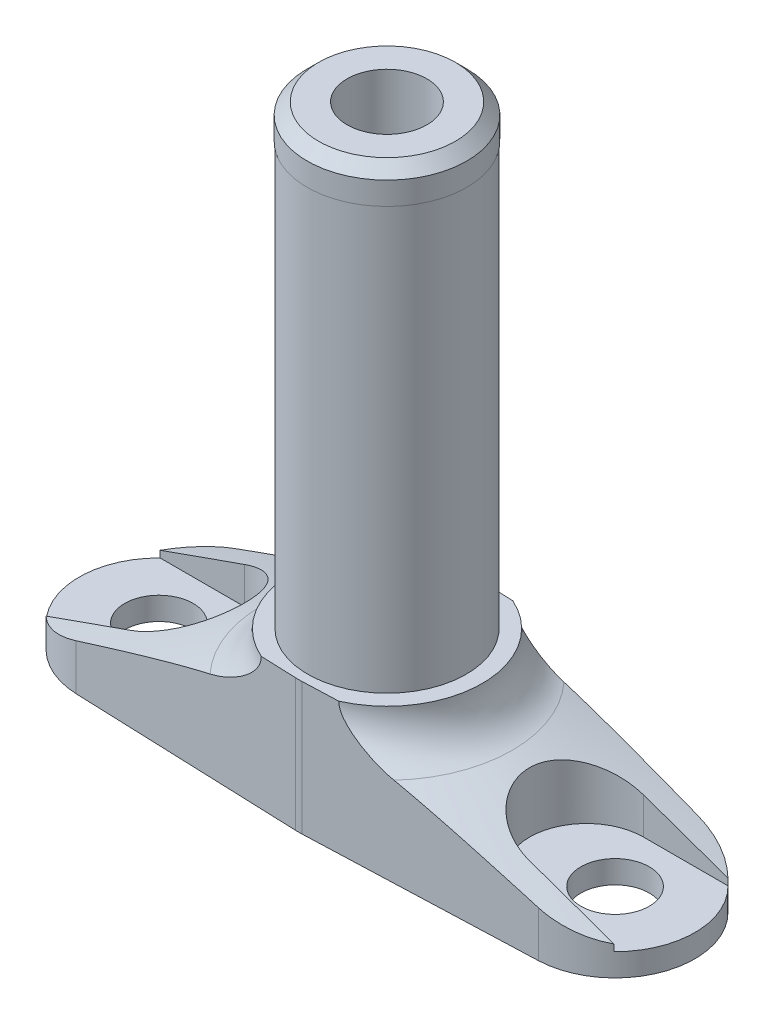
from build123d import *

# Parameters (mm, degrees)
SZKIC1_W                        = 27
SZKIC1_H                        = 25
ZAOKR_GLENIE1_R                 = 4
SZKIC4_R                        = 3
WYTNIJ_WYCI_GNI_CIE3_DEPTH      = 24.0000001
WYTNIJ_WYCI_GNI_CIE3_DEPTH_BACK = 3
WYTNIJ_WYCI_GNI_CIE2_DEPTH      = 24.0000001
SZKIC5_OUTSIDE_W                = 72.072
SZKIC5_OUTSIDE_H                = 72.072
WYTNIJ_WYCI_GNI_CIE4_DEPTH      = 26.0000001
SZKIC8_W                        = 8.35
SZKIC8_H                        = 13.411124978
SZKIC10_R                       = 3.5
WYTNIJ_WYCI_GNI_CIE5_DEPTH      = 52.588875122


with BuildPart() as part:
    # Szkic1 → Obrót1 (revolve)
    with BuildSketch(Plane.XY):
        with Locations((13.5, 12.5)):
            Rectangle(SZKIC1_W, SZKIC1_H)
    revolve(axis=Axis((0, 0, 0), (0, 1, 0)))

    # Szkic2 → Wycięcie-obrót1 (revolve, cut)
    with BuildSketch(Plane.XY):
        Polygon((27, 25), (27, 2), (8.35, 8.788044869), (8.35, 25), align=None)
    revolve(axis=Axis((0, 0, 0), (0, 1, 0)), mode=Mode.SUBTRACT)

    # Zaokrąglenie1
    zaokr_glenie1_edges = [part.edges().sort_by_distance(p)[0] for p in [
        (-8.35, 8.788044869, 0),
    ]]
    fillet(zaokr_glenie1_edges, radius=ZAOKR_GLENIE1_R)

    # Szkic4 → Wytnij-wyciągnięcie3 (cut, two sides)
    with BuildSketch(Plane(origin=(0, 2, 0), x_dir=(1, 0, 0), z_dir=(0, 1, 0))) as wytnij_wyci_gni_cie3_sk:
        with Locations((-20, 0)):
            Circle(SZKIC4_R)
        with Locations((20, 0)):
            Circle(SZKIC4_R)
    extrude(amount=WYTNIJ_WYCI_GNI_CIE3_DEPTH, mode=Mode.SUBTRACT)
    extrude(wytnij_wyci_gni_cie3_sk.sketch, amount=-WYTNIJ_WYCI_GNI_CIE3_DEPTH_BACK, mode=Mode.SUBTRACT)

    # Szkic3 → Wytnij-wyciągnięcie2 (cut, through all)
    with BuildSketch(Plane(origin=(0, 2, 0), x_dir=(1, 0, 0), z_dir=(0, 1, 0))):
        with BuildLine():
            Line((-17.5, 5), (-26.532998323, 5))
            ThreePointArc((-26.532998323, 5), (-27, 0), (-26.532998323, -5))
            Line((-26.532998323, -5), (-17.5, -5))
            ThreePointArc((-17.5, -5), (-12.5, 0), (-17.5, 5))
        make_face()
        with BuildLine():
            Line((17.5, 5), (26.532998323, 5))
            ThreePointArc((26.532998323, 5), (27, 0), (26.532998323, -5))
            Line((26.532998323, -5), (17.5, -5))
            ThreePointArc((17.5, -5), (12.5, 0), (17.5, 5))
        make_face()
    extrude(amount=WYTNIJ_WYCI_GNI_CIE2_DEPTH, mode=Mode.SUBTRACT)

    # Szkic5 outside → Wytnij-wyciągnięcie4 (cut, through all)
    with BuildSketch(Plane.XZ):
        Rectangle(SZKIC5_OUTSIDE_W, SZKIC5_OUTSIDE_H)
        with BuildLine():
            Line((-20.2625, 6.995076393), (-0.290625, 7.744548864))
            ThreePointArc((-0.290625, 7.744548864), (0, 7.75), (0.290625, 7.744548864))
            Line((0.290625, 7.744548864), (20.2625, 6.995076393))
            ThreePointArc((20.2625, 6.995076393), (27, 0), (20.2625, -6.995076393))
            Line((20.2625, -6.995076393), (0.290625, -7.744548864))
            ThreePointArc((0.290625, -7.744548864), (0, -7.75), (-0.290625, -7.744548864))
            Line((-0.290625, -7.744548864), (-20.2625, -6.995076393))
            ThreePointArc((-20.2625, -6.995076393), (-27, 0), (-20.2625, 6.995076393))
        make_face(mode=Mode.SUBTRACT)
    extrude(amount=-WYTNIJ_WYCI_GNI_CIE4_DEPTH, mode=Mode.SUBTRACT)

    # Szkic8 → Wycięcie-obrót2 (revolve, cut)
    with BuildSketch(Plane.XY):
        with Locations((4.175, 18.294437511)):
            Rectangle(SZKIC8_W, SZKIC8_H)
    revolve(axis=Axis((0, 25, 0), (0, -1, 0)), mode=Mode.SUBTRACT)

    # Szkic9 → Obrót2 (revolve)
    with BuildSketch(Plane.XY):
        Polygon((6, 51.588875022), (0, 51.588875022), (0, 11.588875022), (6.95, 11.588875022), (6.95, 48.588875022), (7, 48.588875022), (7, 50.588875022), align=None)
    revolve(axis=Axis((0, 11.588875022, 0), (0, 1, 0)))

    # Szkic10 → Wytnij-wyciągnięcie5 (cut, through all)
    with BuildSketch(Plane(origin=(0, 51.588875022, 0), x_dir=(1, 0, 0), z_dir=(0, 1, 0))):
        Circle(SZKIC10_R)
    extrude(amount=-WYTNIJ_WYCI_GNI_CIE5_DEPTH, mode=Mode.SUBTRACT)


solid = part.part
